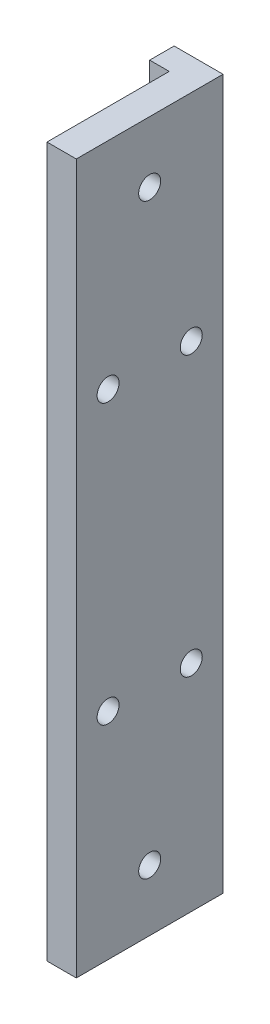
from build123d import *

# Parameters (mm, degrees)
BOSS_EXTRUDE1_DEPTH  = 145
M4_CLEARANCE_HOLE1_D = 4.5
HOLE1_D              = 4.5
HOLE1_DEPTH          = 6
SKETCH8_W            = 5
SKETCH8_H            = 145
CUT_EXTRUDE1_DEPTH   = 4


with BuildPart() as part:
    # Sketch1 → Boss-Extrude1 (new body)
    with BuildSketch(Plane(origin=(0, 260, 0), x_dir=(-1, 0, 0), z_dir=(0, -1, 0))):
        Polygon((71.5, -127.5), (61.5, -127.5), (61.5, -97.5), (71.5, -97.5), (71.5, -102.5), (67.5, -102.5), (67.5, -122.5), (71.5, -122.5), align=None)
    extrude(amount=BOSS_EXTRUDE1_DEPTH)

    # M4 Clearance Hole1 (through all)
    with Locations(Plane(origin=(-61.5, 0, 0), x_dir=(0, 0, -1), z_dir=(1, 0, 0))):
        with Locations((-112.5, 247.5), (-112.5, 127.5)):
            Hole(M4_CLEARANCE_HOLE1_D / 2)

    # Hole1
    with Locations(Plane(origin=(-61.5, 0, 0), x_dir=(0, 0, -1), z_dir=(1, 0, 0))):
        with Locations((-104, 216), (-121, 216), (-104, 159), (-121, 159)):
            Hole(HOLE1_D / 2, depth=HOLE1_DEPTH)

    # Sketch8 → Cut-Extrude1 (cut)
    with BuildSketch(Plane.ZY.offset(71.5)):
        with Locations((125, 187.5)):
            Rectangle(SKETCH8_W, SKETCH8_H)
    extrude(amount=-CUT_EXTRUDE1_DEPTH, mode=Mode.SUBTRACT)


solid = part.part
